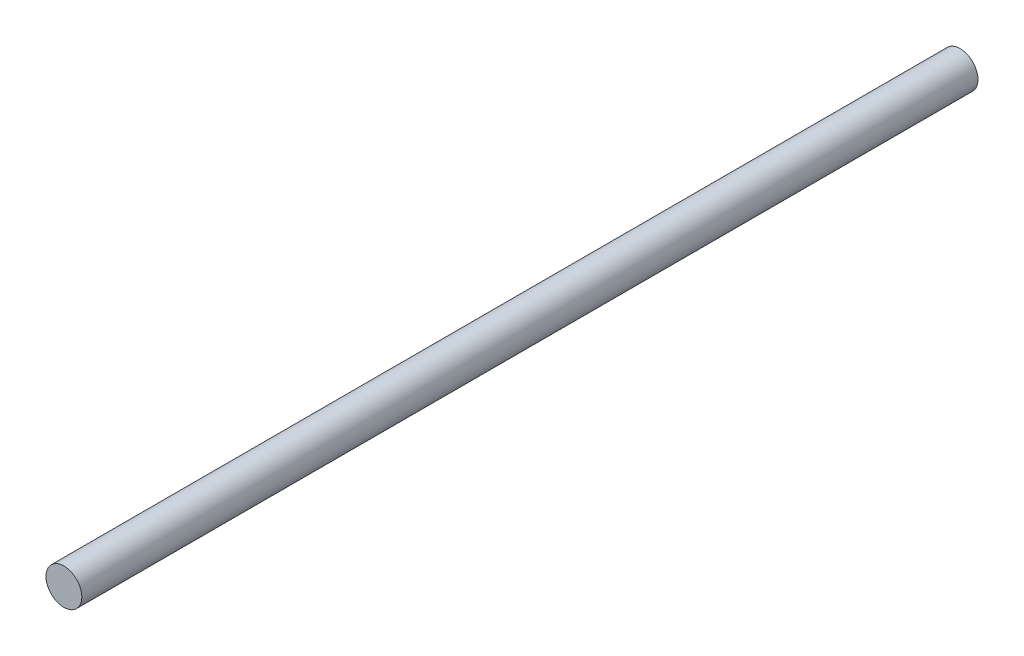
from build123d import *

# Parameters (mm, degrees)
SKETCH1_R           = 1.5
BOSS_EXTRUDE1_DEPTH = 75


with BuildPart() as part:
    # Sketch1 → Boss-Extrude1 (new body)
    with BuildSketch(Plane.XY):
        with Locations((0, 2.5)):
            Circle(SKETCH1_R)
    extrude(amount=BOSS_EXTRUDE1_DEPTH)


solid = part.part
